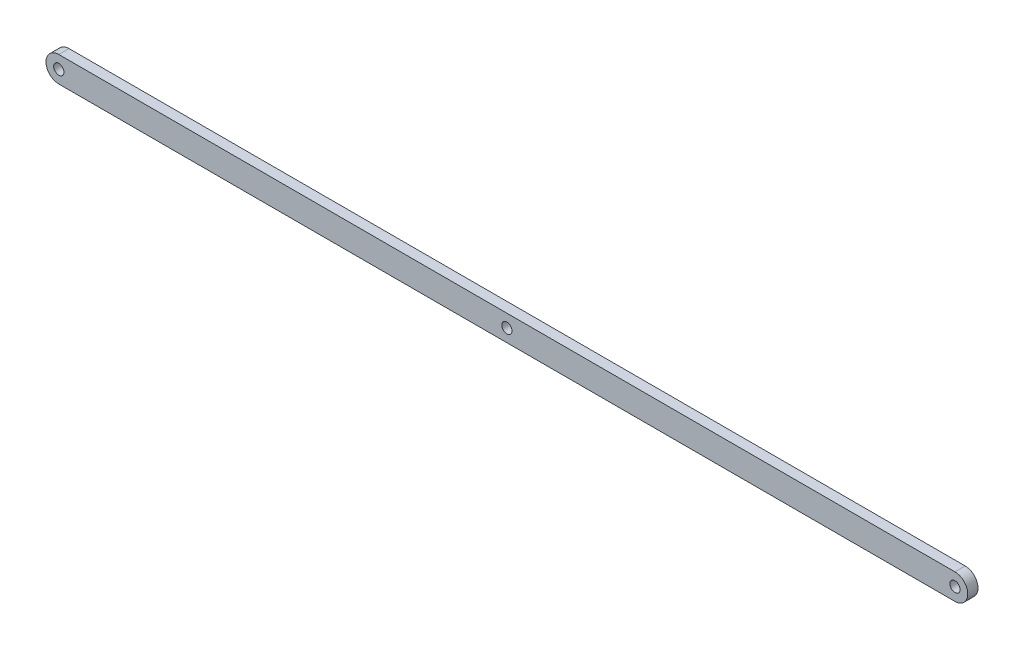
from build123d import *

# Parameters (mm, degrees)
SKETCH1_R           = 1.27
BOSS_EXTRUDE1_DEPTH = 2.54


with BuildPart() as part:
    # Sketch1 → Boss-Extrude1 (new body)
    with BuildSketch(Plane.XY):
        with BuildLine():
            Line((-111.125, -3.175), (111.125, -3.175))
            ThreePointArc((111.125, -3.175), (114.3, 0), (111.125, 3.175))
            Line((111.125, 3.175), (-111.125, 3.175))
            ThreePointArc((-111.125, 3.175), (-114.3, 0), (-111.125, -3.175))
        make_face()
        with Locations((-111.125, 0)):
            Circle(SKETCH1_R, mode=Mode.SUBTRACT)
        Circle(SKETCH1_R, mode=Mode.SUBTRACT)
        with Locations((111.125, 0)):
            Circle(SKETCH1_R, mode=Mode.SUBTRACT)
    extrude(amount=BOSS_EXTRUDE1_DEPTH)


solid = part.part
